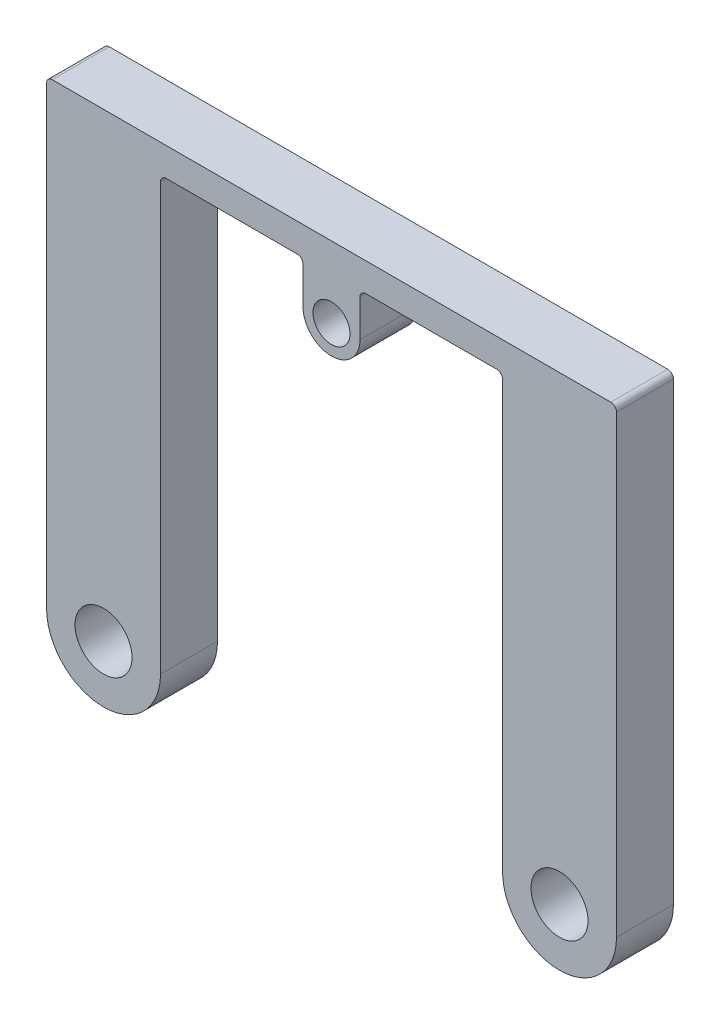
from build123d import *

# Parameters (mm, degrees)
SKETCH1_W           = 60
SKETCH1_H           = 5
SKETCH1_R           = 10
SKETCH1_R_2         = 5
BOSS_EXTRUDE1_DEPTH = 5
SKETCH2_R           = 3.25
BOSS_EXTRUDE2_DEPTH = 10
FILLET1_R           = 1


with BuildPart() as part:
    # Sketch1 → Boss-Extrude1 (new, symmetric)
    with BuildSketch(Plane.XY):
        with BuildLine():
            Line((-50, 80.817230765), (-50, 0))
            ThreePointArc((-50, 0), (-40, 10), (-30, 0))
            Line((-30, 0), (-30, 75.817230765))
            Line((-30, 75.817230765), (-30, 80.817230765))
            Line((-30, 80.817230765), (-50, 80.817230765))
        make_face()
        with Locations((0, 78.317230765)):
            Rectangle(SKETCH1_W, SKETCH1_H)
        with BuildLine():
            Line((50, 80.817230765), (30, 80.817230765))
            Line((30, 80.817230765), (30, 75.817230765))
            Line((30, 75.817230765), (30, 0))
            ThreePointArc((30, 0), (40, 10), (50, 0))
            Line((50, 0), (50, 80.817230765))
        make_face()
        with Locations((-40, 0)):
            Circle(SKETCH1_R)
        with Locations((-40, 0)):
            Circle(SKETCH1_R_2, mode=Mode.SUBTRACT)
        with Locations((40, 0)):
            Circle(SKETCH1_R)
        with Locations((40, 0)):
            Circle(SKETCH1_R_2, mode=Mode.SUBTRACT)
    extrude(amount=BOSS_EXTRUDE1_DEPTH, both=True)

    # Sketch2 → Boss-Extrude2 (add)
    with BuildSketch(Plane.XY.offset(5)):
        with BuildLine():
            Line((-5, 75.817230765), (-5, 68.317230765))
            ThreePointArc((-5, 68.317230765), (0, 63.317230765), (5, 68.317230765))
            Line((5, 68.317230765), (5, 75.817230765))
            Line((5, 75.817230765), (-5, 75.817230765))
        make_face()
        with Locations((0, 68.317230765)):
            Circle(SKETCH2_R, mode=Mode.SUBTRACT)
    extrude(amount=-BOSS_EXTRUDE2_DEPTH)

    # Fillet1
    fillet1_edges = [part.edges().sort_by_distance(p)[0] for p in [
        (-50, 80.817230765, 0),
        (50, 80.817230765, 0),
        (30, 75.817230765, 0),
        (-30, 75.817230765, 0),
        (-5, 75.817230765, 0),
        (5, 75.817230765, 0),
    ]]
    fillet(fillet1_edges, radius=FILLET1_R)


solid = part.part
